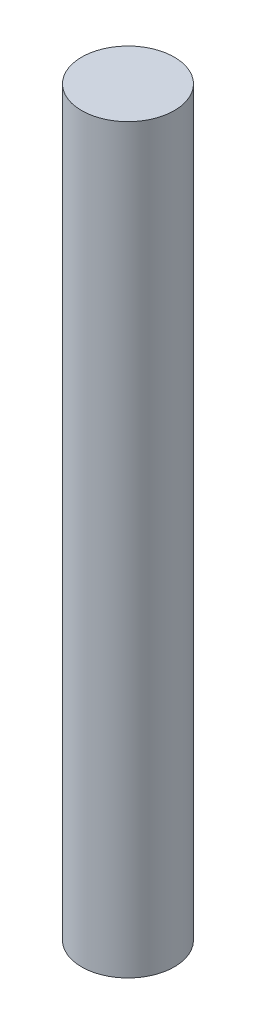
from build123d import *

# Parameters (mm, degrees)
CROQUIS1_R              = 12.5
SALIENTE_EXTRUIR1_DEPTH = 200


with BuildPart() as part:
    # Croquis1 → Saliente-Extruir1 (new body)
    with BuildSketch(Plane(origin=(0, 0, 0), x_dir=(1, 0, 0), z_dir=(0, 1, 0))):
        Circle(CROQUIS1_R)
    extrude(amount=SALIENTE_EXTRUIR1_DEPTH)


solid = part.part
